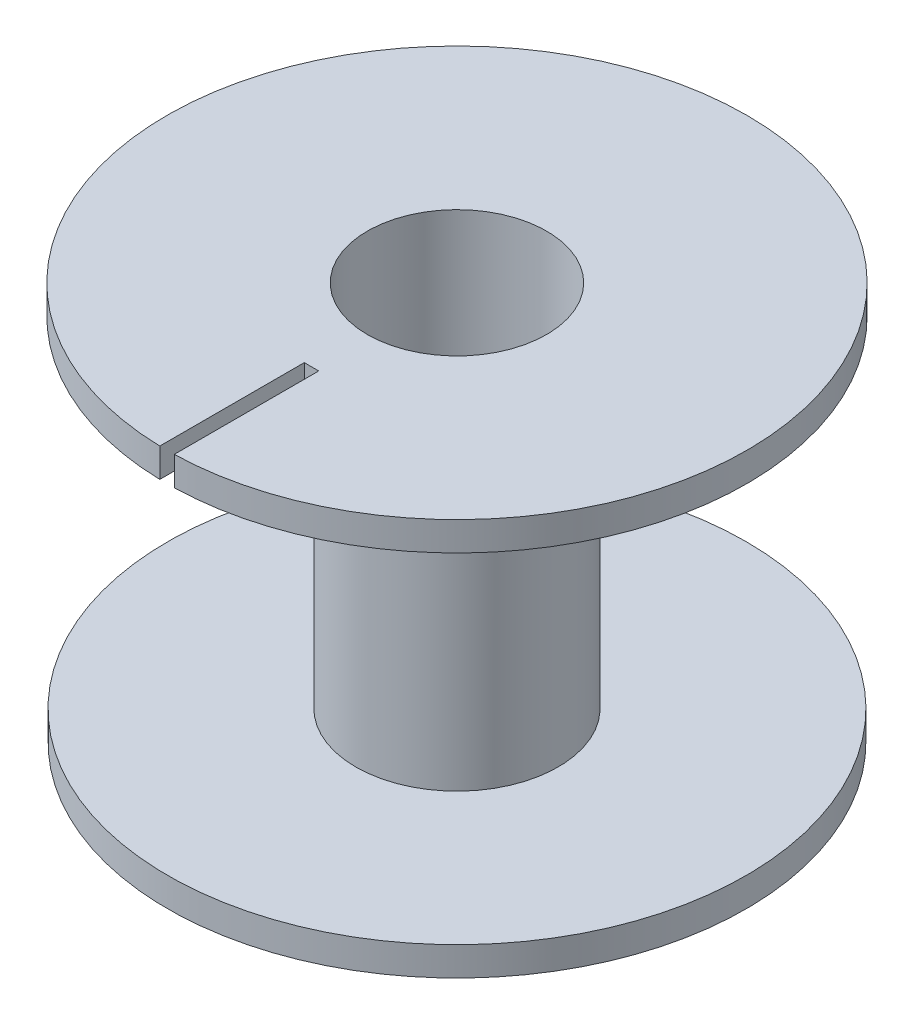
from build123d import *

# Parameters (mm, degrees)
EXTRUDE_3_DEPTH     = 2
SKETCH_5_R          = 6.2
CUT_EXTRUDE_2_DEPTH = 2
SKETCH_6_R          = 7
EXTRUDE_6_DEPTH     = 23.5
SKETCH_7_R          = 6.2
CUT_EXTRUDE_3_DEPTH = 23.5
SKETCH_8_R          = 20
EXTRUDE_7_DEPTH     = 2
SKETCH_9_R          = 6.2
CUT_EXTRUDE_4_DEPTH = 2


with BuildPart() as part:
    # 草图3 → 凸台-拉伸3 (new body)
    with BuildSketch(Plane(origin=(0, 0, 0), x_dir=(1, 0, 0), z_dir=(0, 1, 0))):
        with BuildLine():
            Line((-0.5, -20.052167872), (-0.5, -10.058400643))
            Line((-0.5, -10.058400643), (0.5, -10.058400643))
            Line((0.5, -10.058400643), (0.5, -20.052167872))
            ThreePointArc((0.5, -20.052167872), (0, 20.058400643), (-0.5, -20.052167872))
        make_face()
    extrude(amount=EXTRUDE_3_DEPTH)

    # 草图5 → 切除-拉伸2 (cut)
    with BuildSketch(Plane(origin=(0, 2, 0), x_dir=(1, 0, 0), z_dir=(0, 1, 0))):
        Circle(SKETCH_5_R)
    extrude(amount=-CUT_EXTRUDE_2_DEPTH, mode=Mode.SUBTRACT)

    # 草图6 → 凸台-拉伸6 (add)
    with BuildSketch(Plane(origin=(0, 0, 0), x_dir=(-1, 0, 0), z_dir=(0, -1, 0))):
        Circle(SKETCH_6_R)
    extrude(amount=EXTRUDE_6_DEPTH)

    # 草图7 → 切除-拉伸3 (cut)
    with BuildSketch(Plane(origin=(0, 0, 0), x_dir=(1, 0, 0), z_dir=(0, 1, 0))):
        Circle(SKETCH_7_R)
    extrude(amount=-CUT_EXTRUDE_3_DEPTH, mode=Mode.SUBTRACT)

    # 草图8 → 凸台-拉伸7 (add)
    with BuildSketch(Plane.XZ.offset(23.5)):
        Circle(SKETCH_8_R)
    extrude(amount=EXTRUDE_7_DEPTH)

    # 草图9 → 切除-拉伸4 (cut)
    with BuildSketch(Plane.XZ.offset(25.5)):
        Circle(SKETCH_9_R)
    extrude(amount=-CUT_EXTRUDE_4_DEPTH, mode=Mode.SUBTRACT)


solid = part.part
